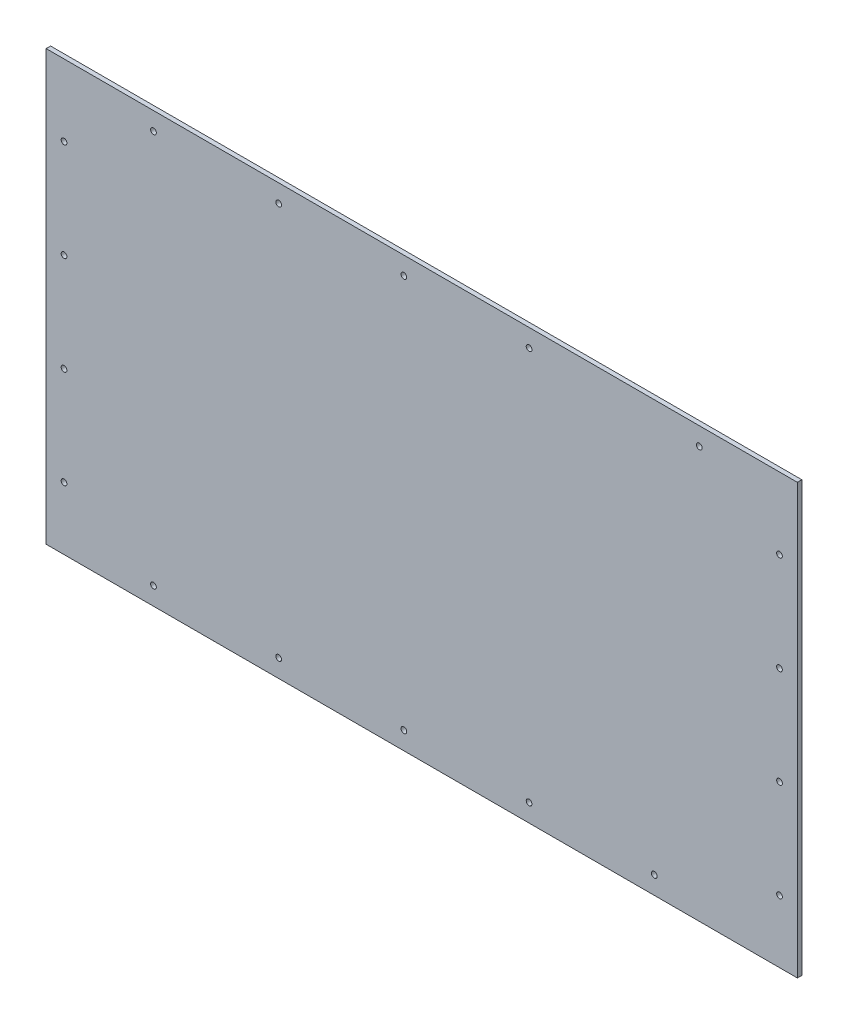
from build123d import *

# Parameters (mm, degrees)
SKETCH1_W           = 533.4
SKETCH1_H           = 304.8
BOSS_EXTRUDE1_DEPTH = 3.175
SKETCH5_R           = 2.032
CUT_EXTRUDE4_DEPTH  = 4.175
SKETCH6_R           = 2.032
CUT_EXTRUDE5_DEPTH  = 3.175


with BuildPart() as part:
    # Sketch1 → Boss-Extrude1 (new body)
    with BuildSketch(Plane.XY):
        with Locations((266.7, 152.4)):
            Rectangle(SKETCH1_W, SKETCH1_H)
    extrude(amount=BOSS_EXTRUDE1_DEPTH)

    # Sketch5 → Cut-Extrude4 (cut, through all)
    with BuildSketch(Plane.XY.offset(3.175)):
        with Locations((76.2, 12.7)):
            Circle(SKETCH5_R)
        with Locations((165.1, 12.7)):
            Circle(SKETCH5_R)
        with Locations((254, 12.7)):
            Circle(SKETCH5_R)
        with Locations((342.9, 12.7)):
            Circle(SKETCH5_R)
        with Locations((431.8, 12.7)):
            Circle(SKETCH5_R)
        with Locations((342.9, 292.1)):
            Circle(SKETCH5_R)
        with Locations((254, 292.1)):
            Circle(SKETCH5_R)
        with Locations((165.1, 292.1)):
            Circle(SKETCH5_R)
        with Locations((76.2, 292.1)):
            Circle(SKETCH5_R)
        with Locations((463.719540129, 292.1)):
            Circle(SKETCH5_R)
    extrude(amount=-CUT_EXTRUDE4_DEPTH, mode=Mode.SUBTRACT)

    # Sketch6 → Cut-Extrude5 (cut)
    with BuildSketch(Plane.XY.offset(3.175)):
        with Locations((12.7, 254)):
            Circle(SKETCH6_R)
        with Locations((12.7, 184.15)):
            Circle(SKETCH6_R)
        with Locations((12.7, 114.3)):
            Circle(SKETCH6_R)
        with Locations((12.7, 44.45)):
            Circle(SKETCH6_R)
        with Locations((520.7, 44.45)):
            Circle(SKETCH6_R)
        with Locations((520.7, 114.3)):
            Circle(SKETCH6_R)
        with Locations((520.7, 184.15)):
            Circle(SKETCH6_R)
        with Locations((520.7, 254)):
            Circle(SKETCH6_R)
    extrude(amount=-CUT_EXTRUDE5_DEPTH, mode=Mode.SUBTRACT)


solid = part.part
